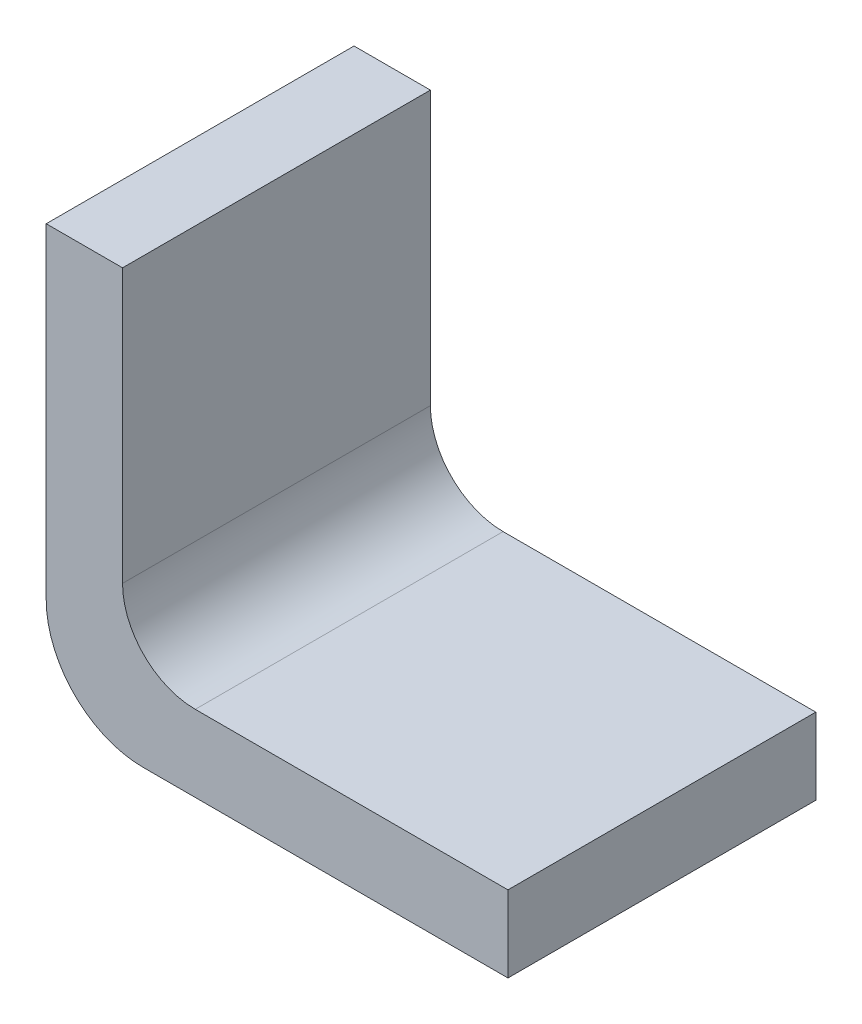
from build123d import *

# Parameters (mm, degrees)
BOSS_EXTRUDE1_DEPTH = 6.35


with BuildPart() as part:
    # Sketch1 → Boss-Extrude1 (new body)
    with BuildSketch(Plane.XY):
        with BuildLine():
            Line((0, 2), (0, 8.7122))
            Line((0, 8.7122), (1.5748, 8.7122))
            Line((1.5748, 8.7122), (1.5748, 3.0748))
            ThreePointArc((1.5748, 3.0748), (2.014139828, 2.014139828), (3.0748, 1.5748))
            Line((3.0748, 1.5748), (9.525, 1.5748))
            Line((9.525, 1.5748), (9.525, 0))
            Line((9.525, 0), (2, 0))
            ThreePointArc((2, 0), (0.585786438, 0.585786438), (0, 2))
        make_face()
    extrude(amount=BOSS_EXTRUDE1_DEPTH)


solid = part.part
